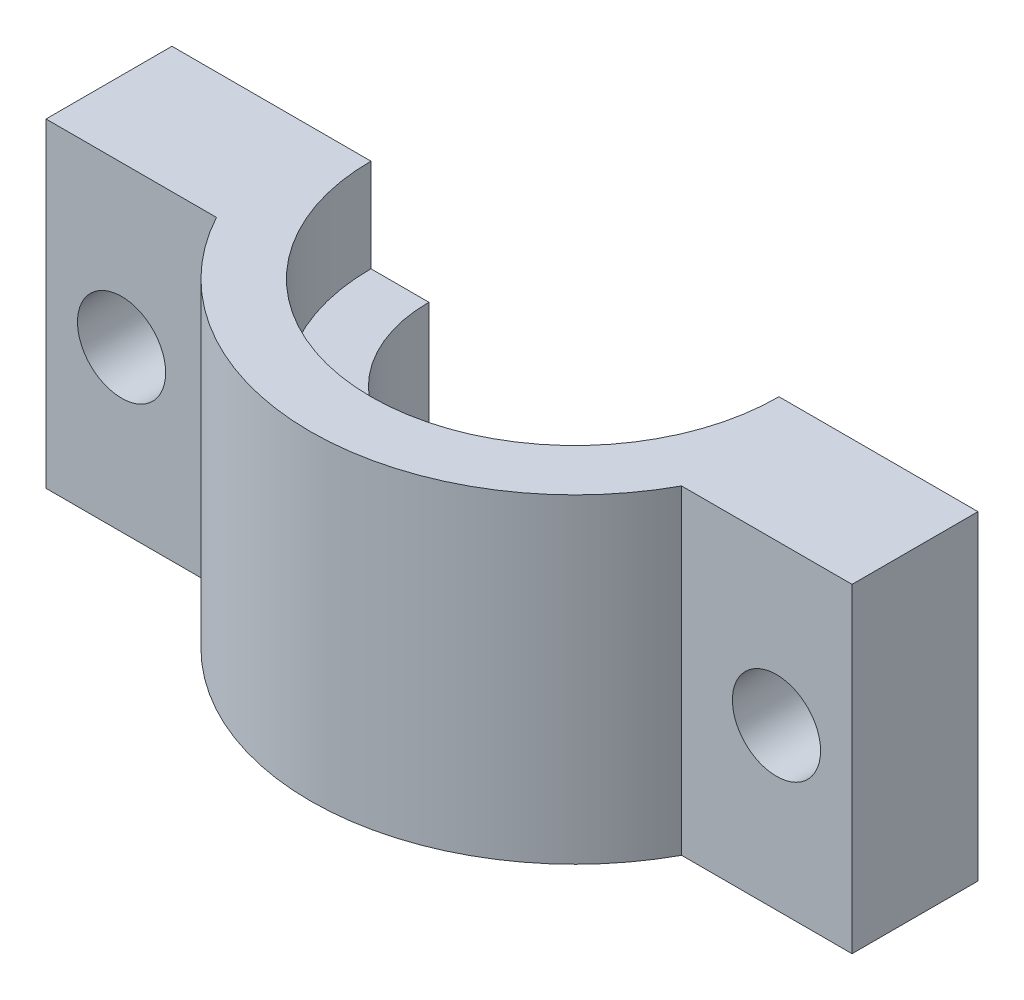
from build123d import *

# Parameters (mm, degrees)
SKETCH1_W           = 32
SKETCH1_H           = 12.7
BOSS_EXTRUDE1_DEPTH = 12
CUT_EXTRUDE1_DEPTH  = 13.7
SKETCH5_R           = 1.75
CUT_EXTRUDE2_DEPTH  = 6


with BuildPart() as part:
    # Sketch1 → Boss-Extrude1 (new body)
    with BuildSketch(Plane.XY):
        Rectangle(SKETCH1_W, SKETCH1_H)
    extrude(amount=BOSS_EXTRUDE1_DEPTH)

    # Sketch3 → Cut-Revolve1 (revolve, cut)
    with BuildSketch(Plane(origin=(0, 0, 0), x_dir=(0, 0, -1), z_dir=(1, 0, 0))):
        Polygon((0, 6.35), (-8.1, 6.35), (-8.1, 2.65), (-5.8, 2.65), (-5.8, -3.35), (-8.1, -3.35), (-8.1, -6.35), (0, -6.35), align=None)
    revolve(axis=Axis((0, 6.35, 0), (0, -1, 0)), mode=Mode.SUBTRACT)

    # Sketch4 → Cut-Extrude1 (cut, through all)
    with BuildSketch(Plane(origin=(0, 6.35, 0), x_dir=(1, 0, 0), z_dir=(0, 1, 0))):
        with BuildLine():
            Line((-16, -5), (-9.233092656, -5))
            ThreePointArc((-9.233092656, -5), (0, -10.5), (9.233092656, -5))
            Line((9.233092656, -5), (16, -5))
            Line((16, -5), (16, -15))
            Line((16, -15), (-16, -15))
            Line((-16, -15), (-16, -5))
        make_face()
    extrude(amount=-CUT_EXTRUDE1_DEPTH, mode=Mode.SUBTRACT)

    # Sketch5 → Cut-Extrude2 (cut, through all)
    with BuildSketch(Plane.XY.offset(5)):
        with Locations((-13, 0)):
            Circle(SKETCH5_R)
        with Locations((13, 0)):
            Circle(SKETCH5_R)
    extrude(amount=-CUT_EXTRUDE2_DEPTH, mode=Mode.SUBTRACT)


solid = part.part
